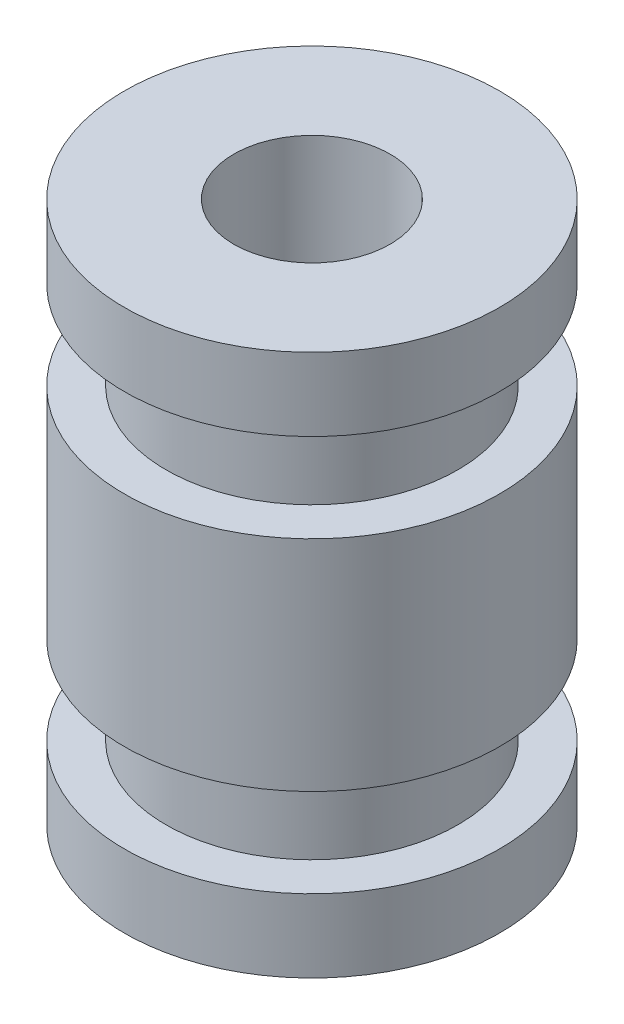
from build123d import *

# Parameters (mm, degrees)
SKETCH2_R               = 1.875
CUT_EXTRUDE1_DEPTH      = 1
CUT_EXTRUDE1_DEPTH_BACK = 14


with BuildPart() as part:
    # Sketch1 → Revolve1 (revolve)
    with BuildSketch(Plane.XY):
        Polygon((0, 0), (0, 13), (4.5, 13), (4.5, 11.25), (3.5, 11.25), (3.5, 9.125), (4.5, 9.125), (4.5, 3.875), (3.5, 3.875), (3.5, 1.75), (4.5, 1.75), (4.5, 0), align=None)
    revolve(axis=Axis((0, 0, 0), (0, 1, 0)))

    # Sketch2 → Cut-Extrude1 (cut, two sides)
    with BuildSketch(Plane(origin=(0, 13, 0), x_dir=(1, 0, 0), z_dir=(0, 1, 0))) as cut_extrude1_sk:
        Circle(SKETCH2_R)
    extrude(amount=CUT_EXTRUDE1_DEPTH, mode=Mode.SUBTRACT)
    extrude(cut_extrude1_sk.sketch, amount=-CUT_EXTRUDE1_DEPTH_BACK, mode=Mode.SUBTRACT)


solid = part.part
